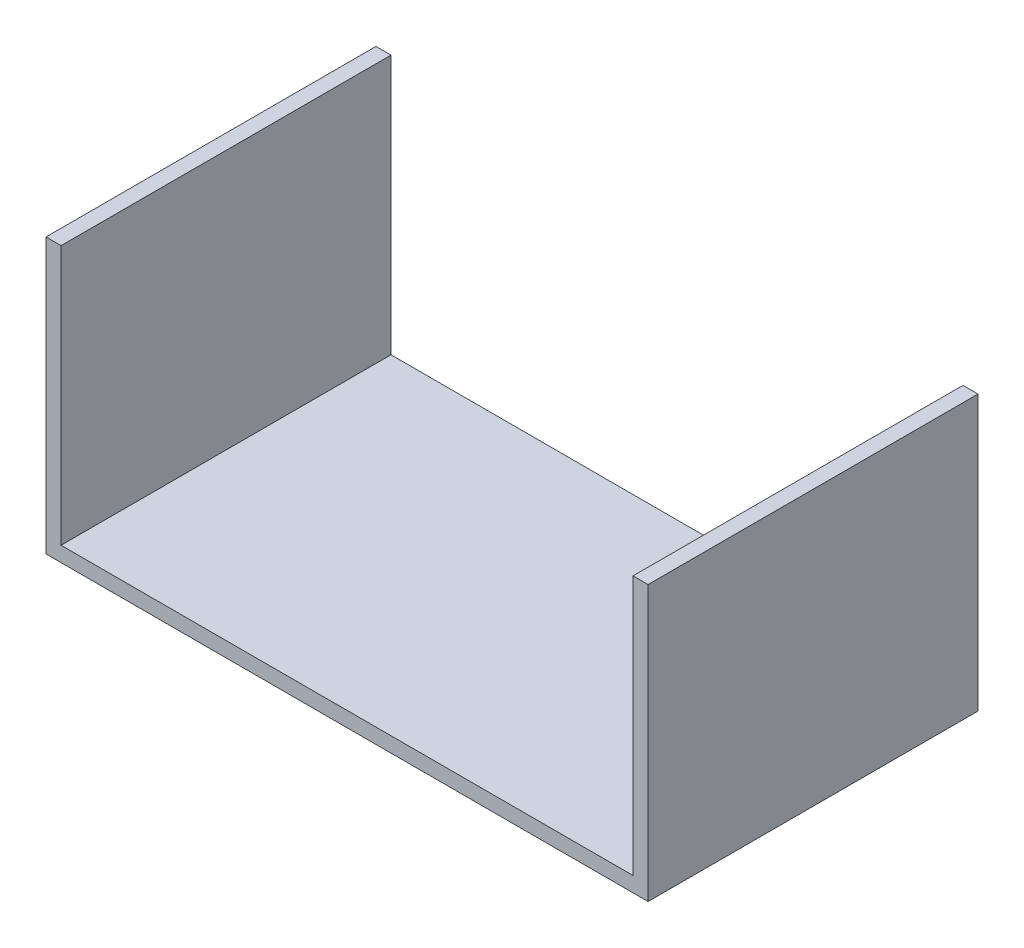
from build123d import *

# Parameters (mm, degrees)
BOSS_EXTRUDE1_DEPTH = 69.596


with BuildPart() as part:
    # Sketch1 → Boss-Extrude1 (new body)
    with BuildSketch(Plane.XY):
        Polygon((-3.175, -3.175), (-3.175, 54.737), (0, 54.737), (0, 51.562), (0, 0), (120.65, 0), (120.65, 54.737), (123.825, 54.737), (123.825, -3.175), align=None)
    extrude(amount=BOSS_EXTRUDE1_DEPTH)


solid = part.part
